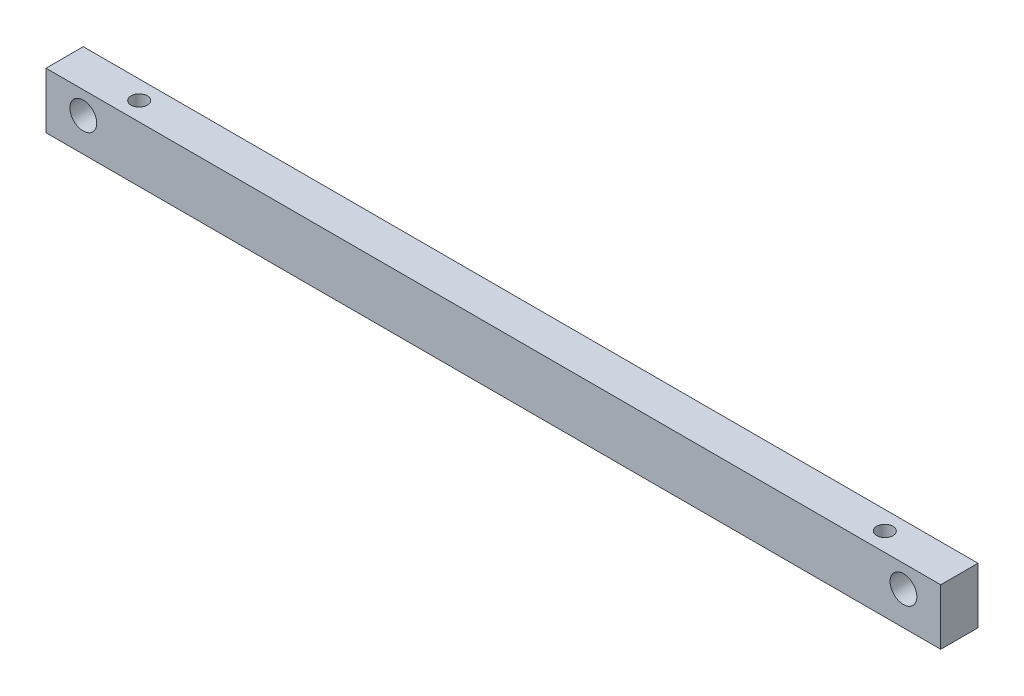
from build123d import *

# Parameters (mm, degrees)
SKETCH1_W               = 12.7
SKETCH1_H               = 19.05
BOSS_EXTRUDE1_DEPTH     = 152.4
SKETCH2_R               = 4.5640625
CUT_EXTRUDE1_DEPTH      = 1
CUT_EXTRUDE1_DEPTH_BACK = 13.7
SKETCH6_R               = 2.778125
CUT_EXTRUDE4_DEPTH      = 1
CUT_EXTRUDE4_DEPTH_BACK = 20.05


with BuildPart() as part:
    # Sketch1 → Boss-Extrude1 (new body, symmetric)
    with BuildSketch(Plane(origin=(0, 0, 0), x_dir=(0, 0, -1), z_dir=(1, 0, 0))):
        Rectangle(SKETCH1_W, SKETCH1_H)
    extrude(amount=BOSS_EXTRUDE1_DEPTH, both=True)

    # Sketch2 → Cut-Extrude1 (cut, two sides)
    with BuildSketch(Plane.XY.offset(6.35)) as cut_extrude1_sk:
        with Locations((139.7, 1.905)):
            Circle(SKETCH2_R)
        with Locations((-139.7, 1.905)):
            Circle(SKETCH2_R)
    extrude(amount=CUT_EXTRUDE1_DEPTH, mode=Mode.SUBTRACT)
    extrude(cut_extrude1_sk.sketch, amount=-CUT_EXTRUDE1_DEPTH_BACK, mode=Mode.SUBTRACT)

    # Sketch6 → Cut-Extrude4 (cut, two sides)
    with BuildSketch(Plane(origin=(0, 9.525, 0), x_dir=(1, 0, 0), z_dir=(0, 1, 0))) as cut_extrude4_sk:
        with Locations((-127, 0)):
            Circle(SKETCH6_R)
        with Locations((127, 0)):
            Circle(SKETCH6_R)
    extrude(amount=CUT_EXTRUDE4_DEPTH, mode=Mode.SUBTRACT)
    extrude(cut_extrude4_sk.sketch, amount=-CUT_EXTRUDE4_DEPTH_BACK, mode=Mode.SUBTRACT)


solid = part.part
